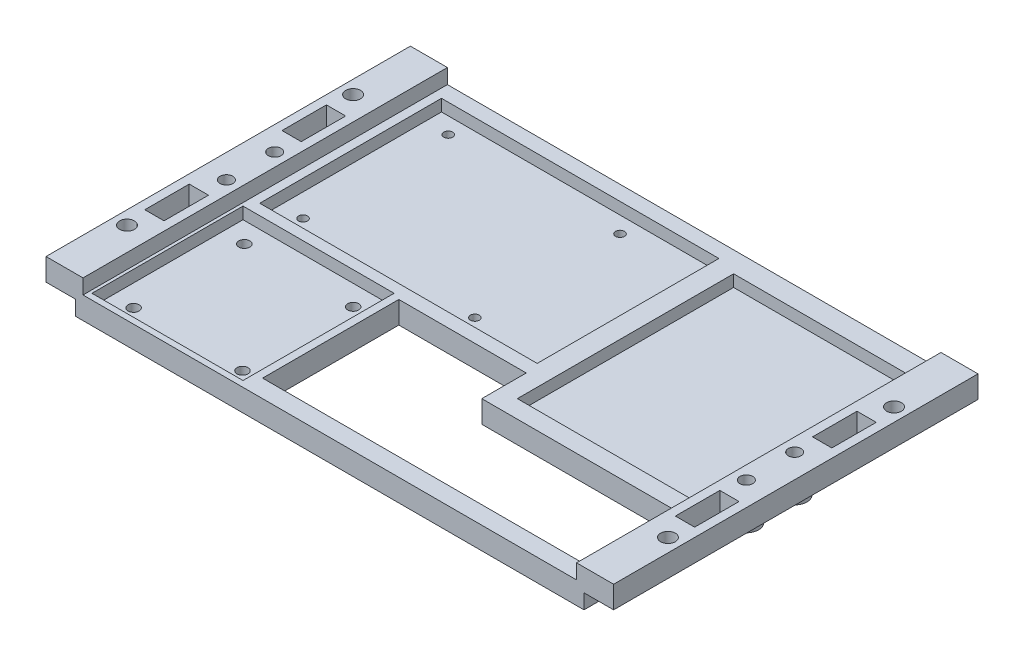
from build123d import *

# Parameters (mm, degrees)
PLATEFRAME_DEPTH          = 150
SKETCH3_R                 = 2.5
HOLESUPPORT_DEPTH         = 13.5
SKETCH4_R                 = 4.15
SKETCH4_R_2               = 2.15
CYLINDRICALSUPPORTS_DEPTH = 12.5
SKETCH5_W                 = 43
SKETCH5_H                 = 43
SKETCH5_W_2               = 89.65
SKETCH5_H_2               = 57.35
SKETCH5_W_3               = 58
SKETCH5_H_3               = 73
ITEMLAYOUT_DEPTH          = 4
HOLECUTOUT_DEPTH          = 7.5
SKETCH7_R                 = 1.5
HOLERASPBERRYPI_DEPTH     = 3.5
SKETCH8_R                 = 1.85
HOLEMOTORDRIVER_DEPTH     = 3.5
SKETCH10_W                = 45
SKETCH10_H                = 45
SKETCH10_W_2              = 43
SKETCH10_H_2              = 43
CUTMOTORDRIVER_DEPTH      = 4
SKETCH11_W                = 93.65
SKETCH11_H                = 61.35
SKETCH11_W_2              = 89.65
SKETCH11_H_2              = 57.35
CUTPASPBERRYPI_DEPTH      = 4
SKETCH12_W                = 191.6
SKETCH12_H                = 13
SKETCH12_H_2              = 14
CUTPLATEEDGES_DEPTH       = 12.5
SKETCH13_W                = 6.5
SKETCH13_H                = 15
CUTSHELLHOLES_DEPTH       = 12.5
SKETCH14_W                = 51
SKETCH14_H                = 51
CUTMOTORDRIVER2_DEPTH     = 4
SKETCH15_R                = 2.5
STANDOFFHOLES_DEPTH       = 13.5
SKETCH16_W                = 2.5
SKETCH16_H                = 28
CUT_EXTRUDE1_DEPTH        = 5


with BuildPart() as part:
    # Sketch2 → PlateFrame (new body)
    with BuildSketch(Plane.XY):
        Polygon((179.1, 12.5), (191.6, 12.5), (191.6, 5), (184.1, 5), (184.1, 0), (7.5, 0), (7.5, 5), (0, 5), (0, 12.5), (12.5, 12.5), (12.5, 7.5), (179.1, 7.5), align=None)
    extrude(amount=PLATEFRAME_DEPTH)

    # Sketch3 → HoleSupport (cut, through all)
    with BuildSketch(Plane(origin=(0, 12.5, 0), x_dir=(1, 0, 0), z_dir=(0, 1, 0))):
        with Locations((8.05, -66.85)):
            Circle(SKETCH3_R)
        with Locations((8.05, -83.15)):
            Circle(SKETCH3_R)
        with Locations((183.55, -66.85)):
            Circle(SKETCH3_R)
        with Locations((183.55, -83.15)):
            Circle(SKETCH3_R)
    extrude(amount=-HOLESUPPORT_DEPTH, mode=Mode.SUBTRACT)

    # Sketch4 → CylindricalSupports (add)
    with BuildSketch(Plane(origin=(0, 12.5, 0), x_dir=(1, 0, 0), z_dir=(0, 1, 0))):
        with Locations((183.55, -66.85)):
            Circle(SKETCH4_R)
        with Locations((183.55, -66.85)):
            Circle(SKETCH4_R_2, mode=Mode.SUBTRACT)
        with Locations((183.55, -83.15)):
            Circle(SKETCH4_R)
        with Locations((183.55, -83.15)):
            Circle(SKETCH4_R_2, mode=Mode.SUBTRACT)
        with Locations((8.05, -66.85)):
            Circle(SKETCH4_R)
        with Locations((8.05, -66.85)):
            Circle(SKETCH4_R_2, mode=Mode.SUBTRACT)
        with Locations((8.05, -83.15)):
            Circle(SKETCH4_R)
        with Locations((8.05, -83.15)):
            Circle(SKETCH4_R_2, mode=Mode.SUBTRACT)
    extrude(amount=-CYLINDRICALSUPPORTS_DEPTH)

    # Sketch5 → ItemLayout (cut)
    with BuildSketch(Plane(origin=(0, 7.5, 0), x_dir=(1, 0, 0), z_dir=(0, 1, 0))):
        with Locations((39, -108.5)):
            Rectangle(SKETCH5_W, SKETCH5_H)
        with Locations((62.325, -48.675)):
            Rectangle(SKETCH5_W_2, SKETCH5_H_2)
        with Locations((145.1, -56.5)):
            Rectangle(SKETCH5_W_3, SKETCH5_H_3)
    extrude(amount=-ITEMLAYOUT_DEPTH, mode=Mode.SUBTRACT)

    # Sketch6 → HoleCutout (cut)
    with BuildSketch(Plane(origin=(0, 7.5, 0), x_dir=(1, 0, 0), z_dir=(0, 1, 0))):
        Polygon((67.1, -84), (110.1, -84), (110.1, -99), (174.1, -99), (174.1, -130), (110.1, -130), (67.1, -130), align=None)
    extrude(amount=-HOLECUTOUT_DEPTH, mode=Mode.SUBTRACT)

    # Sketch7 → HoleRaspberryPi (cut)
    with BuildSketch(Plane(origin=(0, 3.5, 0), x_dir=(1, 0, 0), z_dir=(0, 1, 0))):
        with Locations((23.26, -23.5)):
            Circle(SKETCH7_R)
        with Locations((23.26, -72.5)):
            Circle(SKETCH7_R)
        with Locations((81.26, -72.5)):
            Circle(SKETCH7_R)
        with Locations((81.26, -23.5)):
            Circle(SKETCH7_R)
    extrude(amount=-HOLERASPBERRYPI_DEPTH, mode=Mode.SUBTRACT)

    # Sketch8 → HoleMotorDriver (cut)
    with BuildSketch(Plane(origin=(0, 3.5, 0), x_dir=(1, 0, 0), z_dir=(0, 1, 0))):
        with Locations((57.56, -127.24)):
            Circle(SKETCH8_R)
        with Locations((57.56, -89.86)):
            Circle(SKETCH8_R)
        with Locations((20.81, -89.86)):
            Circle(SKETCH8_R)
        with Locations((20.81, -127.24)):
            Circle(SKETCH8_R)
    extrude(amount=-HOLEMOTORDRIVER_DEPTH, mode=Mode.SUBTRACT)

    # Sketch10 → CutMotorDriver (cut)
    with BuildSketch(Plane(origin=(0, 7.5, 0), x_dir=(1, 0, 0), z_dir=(0, 1, 0))):
        with Locations((39, -108.5)):
            Rectangle(SKETCH10_W, SKETCH10_H)
        with Locations((39, -108.5)):
            Rectangle(SKETCH10_W_2, SKETCH10_H_2, mode=Mode.SUBTRACT)
    extrude(amount=-CUTMOTORDRIVER_DEPTH, mode=Mode.SUBTRACT)

    # Sketch11 → CutPaspberryPi (cut)
    with BuildSketch(Plane(origin=(0, 7.5, 0), x_dir=(1, 0, 0), z_dir=(0, 1, 0))):
        with Locations((62.325, -48.675)):
            Rectangle(SKETCH11_W, SKETCH11_H)
        with Locations((62.325, -48.675)):
            Rectangle(SKETCH11_W_2, SKETCH11_H_2, mode=Mode.SUBTRACT)
    extrude(amount=-CUTPASPBERRYPI_DEPTH, mode=Mode.SUBTRACT)

    # Sketch12 → CutPlateEdges (cut)
    with BuildSketch(Plane(origin=(0, 12.5, 0), x_dir=(1, 0, 0), z_dir=(0, 1, 0))):
        with Locations((95.8, -6.5)):
            Rectangle(SKETCH12_W, SKETCH12_H)
        with Locations((95.8, -143)):
            Rectangle(SKETCH12_W, SKETCH12_H_2)
    extrude(amount=-CUTPLATEEDGES_DEPTH, mode=Mode.SUBTRACT)

    # Sketch13 → CutShellHoles (cut)
    with BuildSketch(Plane(origin=(0, 12.5, 0), x_dir=(1, 0, 0), z_dir=(0, 1, 0))):
        with Locations((6.25, -51.85)):
            Rectangle(SKETCH13_W, SKETCH13_H)
        with Locations((6.25, -98.15)):
            Rectangle(SKETCH13_W, SKETCH13_H)
        with Locations((185.35, -51.85)):
            Rectangle(SKETCH13_W, SKETCH13_H)
        with Locations((185.35, -98.15)):
            Rectangle(SKETCH13_W, SKETCH13_H)
    extrude(amount=-CUTSHELLHOLES_DEPTH, mode=Mode.SUBTRACT)

    # Sketch14 → CutMotorDriver2 (cut)
    with BuildSketch(Plane(origin=(0, 7.5, 0), x_dir=(1, 0, 0), z_dir=(0, 1, 0))):
        with Locations((39, -108.5)):
            Rectangle(SKETCH14_W, SKETCH14_H)
    extrude(amount=-CUTMOTORDRIVER2_DEPTH, mode=Mode.SUBTRACT)

    # Sketch15 → StandoffHoles (cut, through all)
    with BuildSketch(Plane(origin=(0, 12.5, 0), x_dir=(1, 0, 0), z_dir=(0, 1, 0))):
        with Locations((4.5, -36.85)):
            Circle(SKETCH15_R)
        with Locations((4.5, -113.15)):
            Circle(SKETCH15_R)
        with Locations((187.1, -113.15)):
            Circle(SKETCH15_R)
        with Locations((187.1, -36.85)):
            Circle(SKETCH15_R)
    extrude(amount=-STANDOFFHOLES_DEPTH, mode=Mode.SUBTRACT)

    # Sketch16 → Cut-Extrude1 (cut)
    with BuildSketch(Plane.XZ):
        with Locations((8.75, 122)):
            Rectangle(SKETCH16_W, SKETCH16_H)
        with Locations((182.85, 122)):
            Rectangle(SKETCH16_W, SKETCH16_H)
        with Locations((182.85, 27)):
            Rectangle(SKETCH16_W, SKETCH16_H)
        with Locations((8.75, 27)):
            Rectangle(SKETCH16_W, SKETCH16_H)
    extrude(amount=-CUT_EXTRUDE1_DEPTH, mode=Mode.SUBTRACT)


solid = part.part
